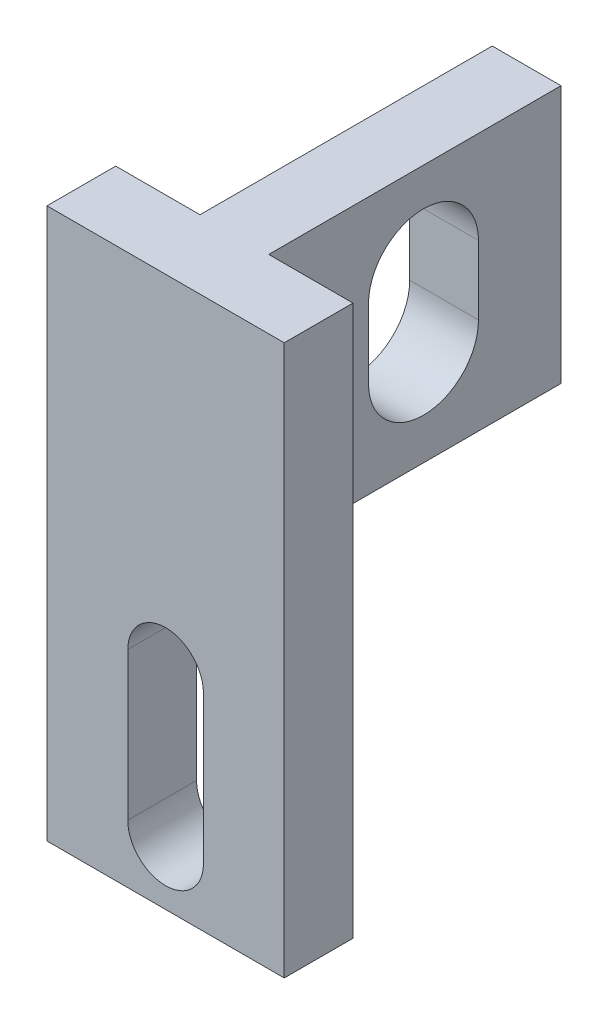
from build123d import *

# Parameters (mm, degrees)
SKETCH7_W                      = 7
SKETCH7_H                      = 16
BOSS_EXTRUDE6_DEPTH            = 2
SKETCH8_W                      = 2
SKETCH8_H                      = 7.5
BOSS_EXTRUDE7_DEPTH            = 8.5
F_2_2_2_2_DIAMETER_HOLE1_D     = 2.2
F_2_2_2_2_DIAMETER_HOLE1_DEPTH = 2
CUT_EXTRUDE3_DEPTH             = 5.5
CUT_EXTRUDE5_DEPTH             = 10
SKETCH18_W                     = 0.05
SKETCH18_H                     = 16
CUT_EXTRUDE6_DEPTH             = 3


with BuildPart() as part:
    # Sketch7 → Boss-Extrude6 (new body)
    with BuildSketch(Plane.XY):
        with Locations((-14.956904704, 13.340209502)):
            Rectangle(SKETCH7_W, SKETCH7_H)
    extrude(amount=BOSS_EXTRUDE6_DEPTH)

    # Sketch8 → Boss-Extrude7 (add)
    with BuildSketch(Plane(origin=(0, 0, 0), x_dir=(-1, 0, 0), z_dir=(0, 0, -1))):
        with Locations((14.956904704, 17.590209502)):
            Rectangle(SKETCH8_W, SKETCH8_H)
    extrude(amount=BOSS_EXTRUDE7_DEPTH)

    # Ø2.2 (2.2) Diameter Hole1
    with Locations(Plane(origin=(0, 0, 0), x_dir=(-1, 0, 0), z_dir=(0, 0, -1))):
        with Locations((14.956904704, 11.340209502)):
            Hole(F_2_2_2_2_DIAMETER_HOLE1_D / 2, depth=F_2_2_2_2_DIAMETER_HOLE1_DEPTH)

    # Sketch15 → Cut-Extrude3 (cut, through all)
    with BuildSketch(Plane(origin=(-13.956904704, 0, 0), x_dir=(0, 0, -1), z_dir=(1, 0, 0))):
        with BuildLine():
            Line((2.9, 16.640209502), (2.9, 18.640209502))
            ThreePointArc((2.9, 18.640209502), (4.5, 20.240209502), (6.1, 18.640209502))
            Line((6.1, 18.640209502), (6.1, 16.640209502))
            ThreePointArc((6.1, 16.640209502), (4.5, 15.040209502), (2.9, 16.640209502))
        make_face()
    extrude(amount=-CUT_EXTRUDE3_DEPTH, mode=Mode.SUBTRACT)

    # Sketch17 → Cut-Extrude5 (cut)
    with BuildSketch(Plane(origin=(0, 0, 0), x_dir=(-1, 0, 0), z_dir=(0, 0, -1))):
        with BuildLine():
            Line((13.856904704, 7.040209502), (13.856904704, 11.340209502))
            Line((13.856904704, 11.340209502), (16.056904704, 11.340209502))
            Line((16.056904704, 11.340209502), (16.056904704, 7.040209502))
            ThreePointArc((16.056904704, 7.040209502), (14.956904704, 5.940209502), (13.856904704, 7.040209502))
        make_face()
    extrude(amount=-CUT_EXTRUDE5_DEPTH, mode=Mode.SUBTRACT)

    # Sketch18 → Cut-Extrude6 (cut, through all)
    with BuildSketch(Plane(origin=(0, 0, 0), x_dir=(-1, 0, 0), z_dir=(0, 0, -1))):
        with Locations((11.481904704, 13.340209502)):
            Rectangle(SKETCH18_W, SKETCH18_H)
        with Locations((18.431904704, 13.340209502)):
            Rectangle(SKETCH18_W, SKETCH18_H)
    extrude(amount=-CUT_EXTRUDE6_DEPTH, mode=Mode.SUBTRACT)


solid = part.part
